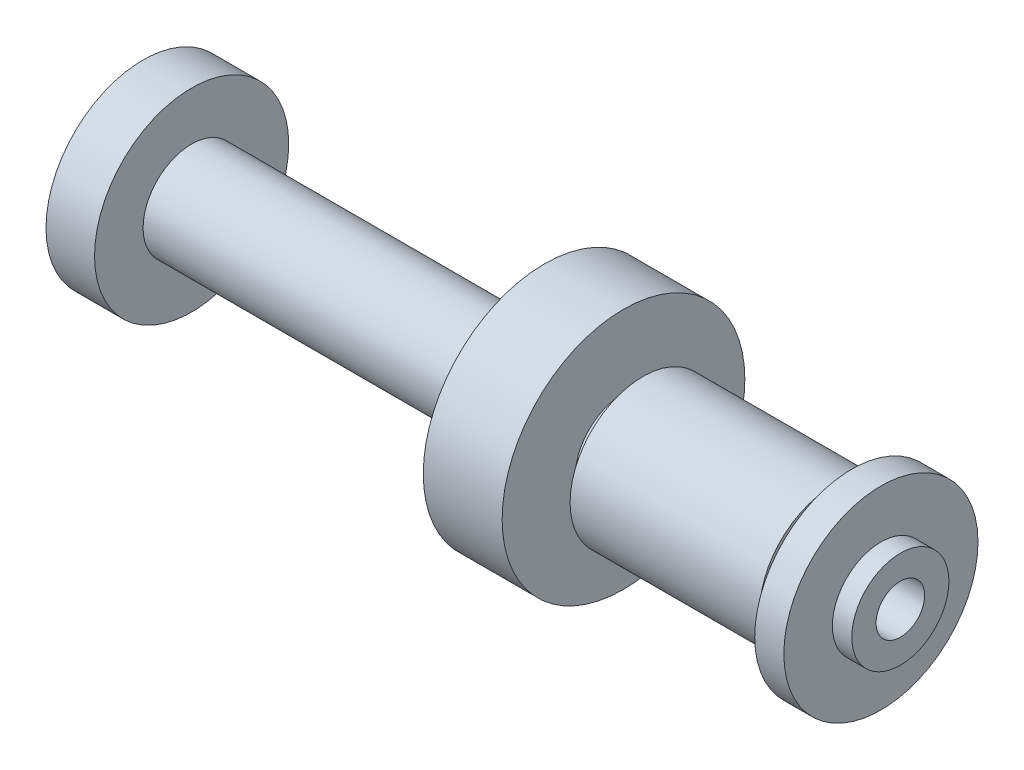
from build123d import *

# Parameters (mm, degrees)
SKETCH2_R               = 3.175
CUT_EXTRUDE1_DEPTH      = 1
CUT_EXTRUDE1_DEPTH_BACK = 102.6


with BuildPart() as part:
    # Sketch1 → Revolve1 (revolve)
    with BuildSketch(Plane.XY):
        Polygon((0, 0), (0, 6.35), (-2.54, 6.35), (-2.54, 12.7), (-6.35, 12.7), (-6.35, 6.35), (-8.89, 6.35), (-8.89, 9.525), (-33.67488639, 9.525), (-33.67488639, 6.35), (-36.21488639, 6.35), (-36.21488639, 15.875), (-46.531378447, 15.875), (-46.531378447, 6.35), (-92.71, 6.35), (-92.71, 12.7), (-99.06, 12.7), (-99.06, 6.35), (-101.6, 6.35), (-101.6, 0), align=None)
    revolve(axis=Axis((0, 0, 0), (1, 0, 0)))

    # Sketch2 → Cut-Extrude1 (cut, two sides)
    with BuildSketch(Plane(origin=(0, 0, 0), x_dir=(0, 0, -1), z_dir=(1, 0, 0))) as cut_extrude1_sk:
        Circle(SKETCH2_R)
    extrude(amount=CUT_EXTRUDE1_DEPTH, mode=Mode.SUBTRACT)
    extrude(cut_extrude1_sk.sketch, amount=-CUT_EXTRUDE1_DEPTH_BACK, mode=Mode.SUBTRACT)


solid = part.part
